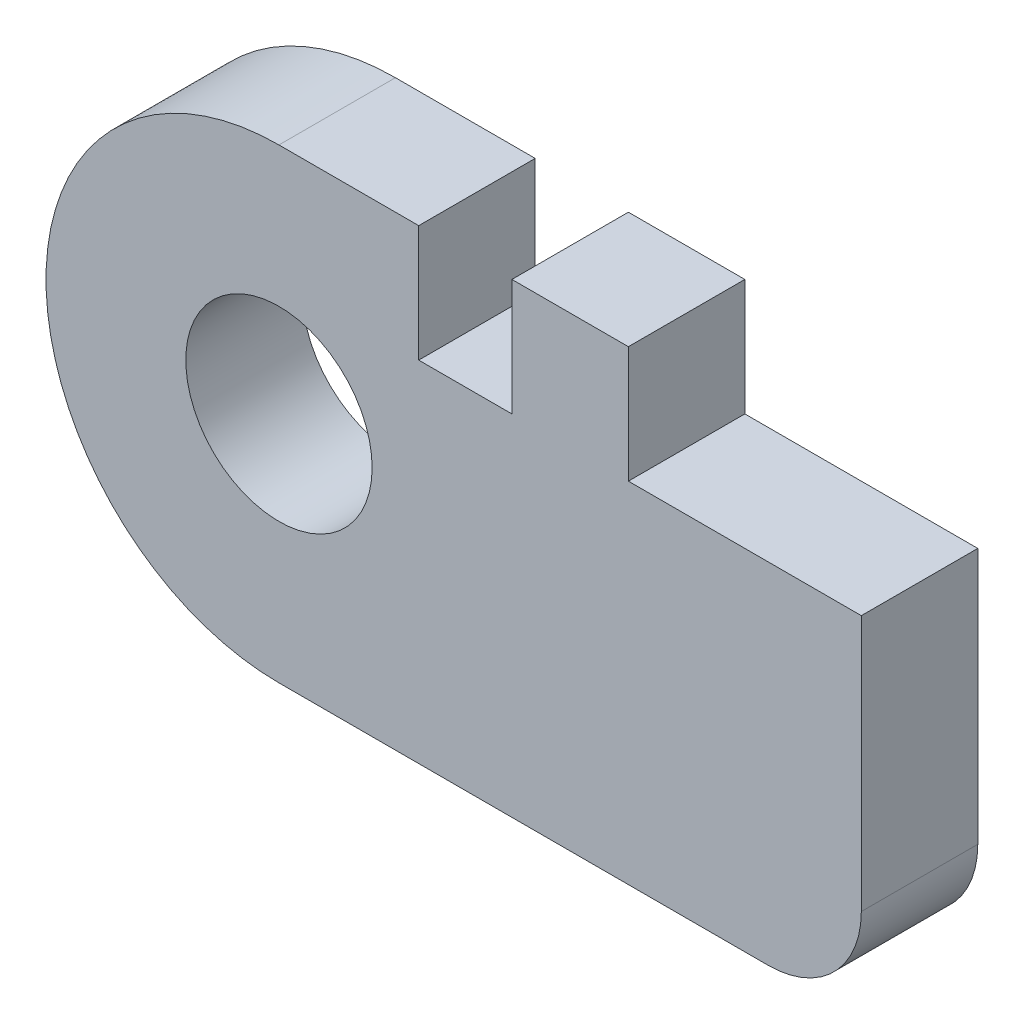
from build123d import *

# Parameters (mm, degrees)
SKETCH1_R           = 4
BOSS_EXTRUDE4_DEPTH = 5


with BuildPart() as part:
    # Sketch1 → Boss-Extrude4 (new body)
    with BuildSketch(Plane.XY):
        with BuildLine():
            Line((22.5, 5), (22.5, -6))
            ThreePointArc((22.5, -6), (21.328427125, -8.828427125), (18.5, -10))
            Line((18.5, -10), (-2.5, -10))
            ThreePointArc((-2.5, -10), (-12.5, 0), (-2.5, 10))
            Line((-2.5, 10), (3.5, 10))
            Line((3.5, 10), (3.5, 5))
            Line((3.5, 5), (7.5, 5))
            Line((7.5, 5), (7.5, 10))
            Line((7.5, 10), (12.5, 10))
            Line((12.5, 10), (12.5, 5))
            Line((12.5, 5), (22.5, 5))
        make_face()
        with Locations((-2.5, 0)):
            Circle(SKETCH1_R, mode=Mode.SUBTRACT)
    extrude(amount=BOSS_EXTRUDE4_DEPTH)


solid = part.part
